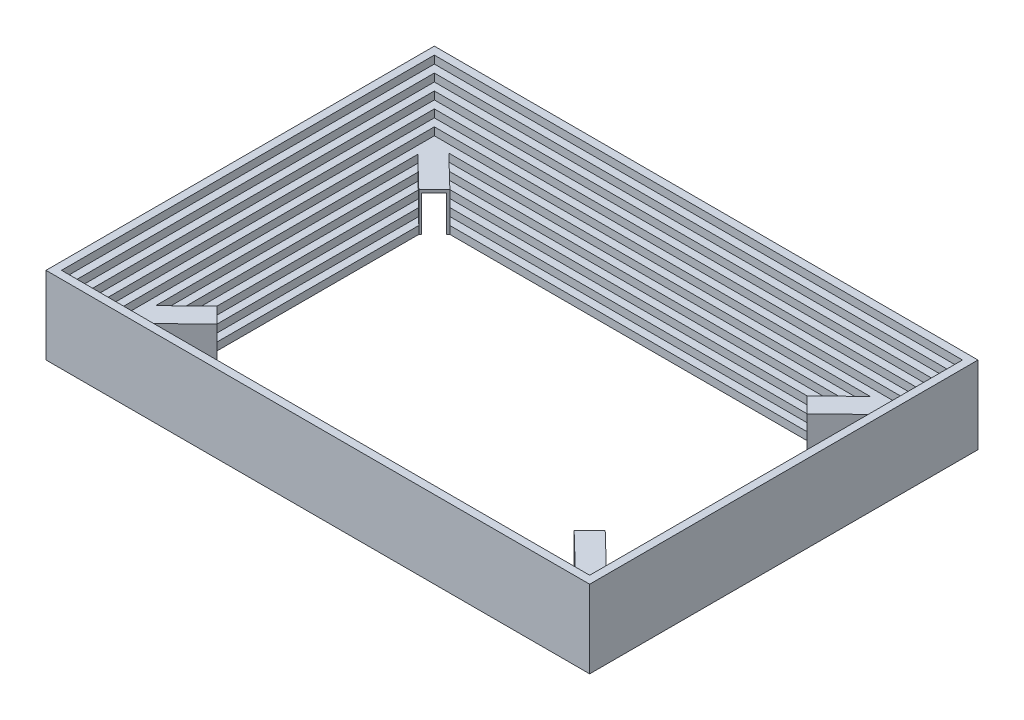
from build123d import *

# Parameters (mm, degrees)
ESQUISSE1_W              = 35000
ESQUISSE1_H              = 25000
ESQUISSE1_W_2            = 25000
ESQUISSE1_H_2            = 15000
BOSS_EXTRU_2_DEPTH       = 5000
ESQUISSE2_W              = 34000
ESQUISSE2_H              = 24000
ENL_V_MAT_EXTRU_1_DEPTH  = 500
ESQUISSE3_W              = 33000
ESQUISSE3_H              = 23000
ENL_V_MAT_EXTRU_2_DEPTH  = 500
ESQUISSE4_W              = 32000
ESQUISSE4_H              = 22000
ENL_V_MAT_EXTRU_3_DEPTH  = 500
ESQUISSE5_W              = 31000
ESQUISSE5_H              = 21000
ENL_V_MAT_EXTRU_4_DEPTH  = 500
ESQUISSE6_W              = 30000
ESQUISSE6_H              = 20000
ENL_V_MAT_EXTRU_5_DEPTH  = 500
ESQUISSE7_W              = 29000
ESQUISSE7_H              = 19000
ENL_V_MAT_EXTRU_6_DEPTH  = 500
ESQUISSE8_W              = 28000
ESQUISSE8_H              = 18000
ENL_V_MAT_EXTRU_7_DEPTH  = 500
ESQUISSE9_W              = 27000
ESQUISSE9_H              = 17000
ENL_V_MAT_EXTRU_8_DEPTH  = 500
ESQUISSE10_W             = 26000
ESQUISSE10_H             = 16000
ENL_V_MAT_EXTRU_9_DEPTH  = 500
BOSS_EXTRU_4_DEPTH       = 2500
ESQUISSE12_W             = 1012.695529181
ESQUISSE12_H             = 2272.385117154
ENL_V_MAT_EXTRU_10_DEPTH = 5000
ESQUISSE13_W             = 1120.580742395
ESQUISSE13_H             = 2341.167166511
ENL_V_MAT_EXTRU_11_DEPTH = 5000
ESQUISSE14_W             = 1194.693774878
ESQUISSE14_H             = 2270.046539735
ENL_V_MAT_EXTRU_12_DEPTH = 5000
ESQUISSE15_W             = 1155.834149298
ESQUISSE15_H             = 2314.592107333
ENL_V_MAT_EXTRU_14_DEPTH = 5000


with BuildPart() as part:
    # Esquisse1 → Boss.-Extru.2 (new body)
    with BuildSketch(Plane(origin=(0, 0, 0), x_dir=(1, 0, 0), z_dir=(0, 1, 0))):
        Rectangle(ESQUISSE1_W, ESQUISSE1_H)
        Rectangle(ESQUISSE1_W_2, ESQUISSE1_H_2, mode=Mode.SUBTRACT)
    extrude(amount=BOSS_EXTRU_2_DEPTH)

    # Esquisse2 → Enlèv. mat.-Extru.1 (cut)
    with BuildSketch(Plane(origin=(0, 5000, 0), x_dir=(1, 0, 0), z_dir=(0, 1, 0))):
        Rectangle(ESQUISSE2_W, ESQUISSE2_H)
    extrude(amount=-ENL_V_MAT_EXTRU_1_DEPTH, mode=Mode.SUBTRACT)

    # Esquisse3 → Enlèv. mat.-Extru.2 (cut)
    with BuildSketch(Plane(origin=(0, 4500, 0), x_dir=(1, 0, 0), z_dir=(0, 1, 0))):
        Rectangle(ESQUISSE3_W, ESQUISSE3_H)
    extrude(amount=-ENL_V_MAT_EXTRU_2_DEPTH, mode=Mode.SUBTRACT)

    # Esquisse4 → Enlèv. mat.-Extru.3 (cut)
    with BuildSketch(Plane(origin=(0, 4000, 0), x_dir=(1, 0, 0), z_dir=(0, 1, 0))):
        Rectangle(ESQUISSE4_W, ESQUISSE4_H)
    extrude(amount=-ENL_V_MAT_EXTRU_3_DEPTH, mode=Mode.SUBTRACT)

    # Esquisse5 → Enlèv. mat.-Extru.4 (cut)
    with BuildSketch(Plane(origin=(0, 3500, 0), x_dir=(1, 0, 0), z_dir=(0, 1, 0))):
        Rectangle(ESQUISSE5_W, ESQUISSE5_H)
    extrude(amount=-ENL_V_MAT_EXTRU_4_DEPTH, mode=Mode.SUBTRACT)

    # Esquisse6 → Enlèv. mat.-Extru.5 (cut)
    with BuildSketch(Plane(origin=(0, 3000, 0), x_dir=(1, 0, 0), z_dir=(0, 1, 0))):
        Rectangle(ESQUISSE6_W, ESQUISSE6_H)
    extrude(amount=-ENL_V_MAT_EXTRU_5_DEPTH, mode=Mode.SUBTRACT)

    # Esquisse7 → Enlèv. mat.-Extru.6 (cut)
    with BuildSketch(Plane(origin=(0, 2500, 0), x_dir=(1, 0, 0), z_dir=(0, 1, 0))):
        Rectangle(ESQUISSE7_W, ESQUISSE7_H)
    extrude(amount=-ENL_V_MAT_EXTRU_6_DEPTH, mode=Mode.SUBTRACT)

    # Esquisse8 → Enlèv. mat.-Extru.7 (cut)
    with BuildSketch(Plane(origin=(0, 2000, 0), x_dir=(1, 0, 0), z_dir=(0, 1, 0))):
        Rectangle(ESQUISSE8_W, ESQUISSE8_H)
    extrude(amount=-ENL_V_MAT_EXTRU_7_DEPTH, mode=Mode.SUBTRACT)

    # Esquisse9 → Enlèv. mat.-Extru.8 (cut)
    with BuildSketch(Plane(origin=(0, 1500, 0), x_dir=(1, 0, 0), z_dir=(0, 1, 0))):
        Rectangle(ESQUISSE9_W, ESQUISSE9_H)
    extrude(amount=-ENL_V_MAT_EXTRU_8_DEPTH, mode=Mode.SUBTRACT)

    # Esquisse10 → Enlèv. mat.-Extru.9 (cut)
    with BuildSketch(Plane(origin=(0, 1000, 0), x_dir=(1, 0, 0), z_dir=(0, 1, 0))):
        Rectangle(ESQUISSE10_W, ESQUISSE10_H)
    extrude(amount=-ENL_V_MAT_EXTRU_9_DEPTH, mode=Mode.SUBTRACT)

    # Esquisse11 → Boss.-Extru.4 (add)
    with BuildSketch(Plane(origin=(0, 2500, 0), x_dir=(1, 0, 0), z_dir=(0, 1, 0))):
        Polygon((-12500, -6500), (-17000, -10850.685111022), (-16154.439354551, -12000), (-11500, -7500), align=None)
        Polygon((-17000, 10850.685111022), (-16154.439354551, 12000), (-11500, 7500), (-12500, 6500), align=None)
        Polygon((12500, 6500), (17000, 10850.685111022), (16154.439354551, 12000), (11500, 7500), align=None)
        Polygon((17000, -10850.685111022), (16154.439354551, -12000), (11500, -7500), (12500, -6500), align=None)
    extrude(amount=-BOSS_EXTRU_4_DEPTH)

    # Esquisse12 → Enlèv. mat.-Extru.10 (cut)
    with BuildSketch(Plane(origin=(9500, 0, -9500), x_dir=(0.707106781, 0, 0.707106781), z_dir=(-0.707106781, 0, 0.707106781))):
        with Locations((3525.233881406, 1136.192558577)):
            Rectangle(ESQUISSE12_W, ESQUISSE12_H)
    extrude(amount=-ENL_V_MAT_EXTRU_10_DEPTH, mode=Mode.SUBTRACT)

    # Esquisse13 → Enlèv. mat.-Extru.11 (cut)
    with BuildSketch(Plane(origin=(9500, 0, 9500), x_dir=(-0.707106781, 0, 0.707106781), z_dir=(-0.707106781, 0, -0.707106781))):
        with Locations((-3543.76036393, 1170.583583256)):
            Rectangle(ESQUISSE13_W, ESQUISSE13_H)
    extrude(amount=-ENL_V_MAT_EXTRU_11_DEPTH, mode=Mode.SUBTRACT)

    # Esquisse14 → Enlèv. mat.-Extru.12 (cut)
    with BuildSketch(Plane(origin=(-9500, 0, 9500), x_dir=(-0.707106781, 0, -0.707106781), z_dir=(0.707106781, 0, -0.707106781))):
        with Locations((3531.730445489, 1135.023269868)):
            Rectangle(ESQUISSE14_W, ESQUISSE14_H)
    extrude(amount=-ENL_V_MAT_EXTRU_12_DEPTH, mode=Mode.SUBTRACT)

    # Esquisse15 → Enlèv. mat.-Extru.14 (cut)
    with BuildSketch(Plane(origin=(-9500, 0, -9500), x_dir=(0.707106781, 0, -0.707106781), z_dir=(0.707106781, 0, 0.707106781))):
        with Locations((-3550.041670603, 1157.296053667)):
            Rectangle(ESQUISSE15_W, ESQUISSE15_H)
    extrude(amount=-ENL_V_MAT_EXTRU_14_DEPTH, mode=Mode.SUBTRACT)


solid = part.part
